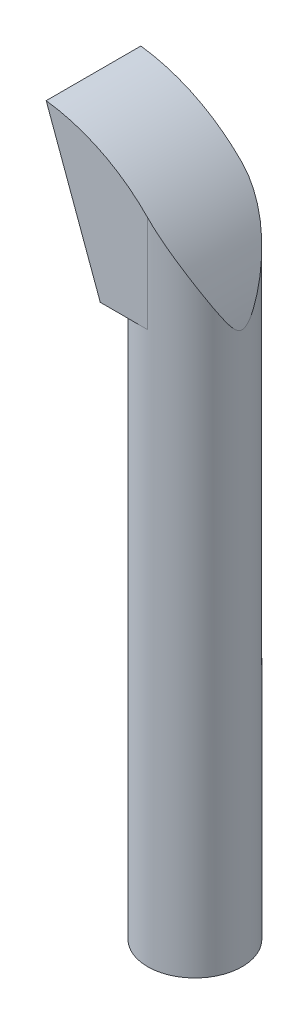
from build123d import *

# Parameters (mm, degrees)
SKETCH1_R                = 13.5
SKETCH1_R_2              = 11
BOSS_EXTRUDE1_DEPTH      = 152.4
SKETCH2_R                = 13.5
BOSS_EXTRUDE2_DEPTH      = 5
BOSS_EXTRUDE3_DEPTH      = 15
BOSS_EXTRUDE3_DEPTH_BACK = 15
CUT_EXTRUDE3_DEPTH       = 60


with BuildPart() as part:
    # Sketch1 → Boss-Extrude1 (new body)
    with BuildSketch(Plane(origin=(0, 0, 0), x_dir=(1, 0, 0), z_dir=(0, 1, 0))):
        Circle(SKETCH1_R)
        Circle(SKETCH1_R_2, mode=Mode.SUBTRACT)
    extrude(amount=BOSS_EXTRUDE1_DEPTH)

    # Sketch2 → Boss-Extrude2 (add)
    with BuildSketch(Plane(origin=(0, 152.4, 0), x_dir=(1, 0, 0), z_dir=(0, 1, 0))):
        Circle(SKETCH2_R)
    extrude(amount=BOSS_EXTRUDE2_DEPTH)

    # Sketch4 → Boss-Extrude3 (add, two sides: drawn at the far end of the back side and taken through both)
    with BuildSketch(Plane.XY.offset(-BOSS_EXTRUDE3_DEPTH_BACK)):
        with BuildLine():
            Line((-11.023106703, 157.4), (13.5, 157.4))
            ThreePointArc((13.5, 157.4), (-0.556148669, 185.669720677), (-28.926428084, 199.52178437))
            Line((-28.926428084, 199.52178437), (-13.5, 157.4))
            Line((-13.5, 157.4), (-11.023106703, 157.4))
        make_face()
    extrude(amount=BOSS_EXTRUDE3_DEPTH + BOSS_EXTRUDE3_DEPTH_BACK)

    # Sketch6 → Cut-Extrude3 (cut)
    with BuildSketch(Plane.XZ.offset(-157.4)):
        with BuildLine():
            Line((0, -13.5), (-22.831524923, -13.5))
            Line((-22.831524923, -13.5), (-32.31073418, -13.5))
            Line((-32.31073418, -13.5), (-41.113501084, -13.5))
            Line((-41.113501084, -13.5), (-41.113501084, -20.862107507))
            Line((-41.113501084, -20.862107507), (-22.423580549, -20.091260403))
            Line((-22.423580549, -20.091260403), (15.387763585, -20.091260403))
            Line((15.387763585, -20.091260403), (15.387763585, 20.06576388))
            Line((15.387763585, 20.06576388), (-22.423580549, 20.06576388))
            Line((-22.423580549, 20.06576388), (-41.113501084, 20.06576388))
            Line((-41.113501084, 20.06576388), (-41.553103928, 13.317013583))
            Line((-41.553103928, 13.317013583), (-30.569316507, 13.5))
            Line((-30.569316507, 13.5), (0, 13.5))
            ThreePointArc((0, 13.5), (13.5, 0), (0, -13.5))
        make_face()
    extrude(amount=-CUT_EXTRUDE3_DEPTH, mode=Mode.SUBTRACT)


solid = part.part
